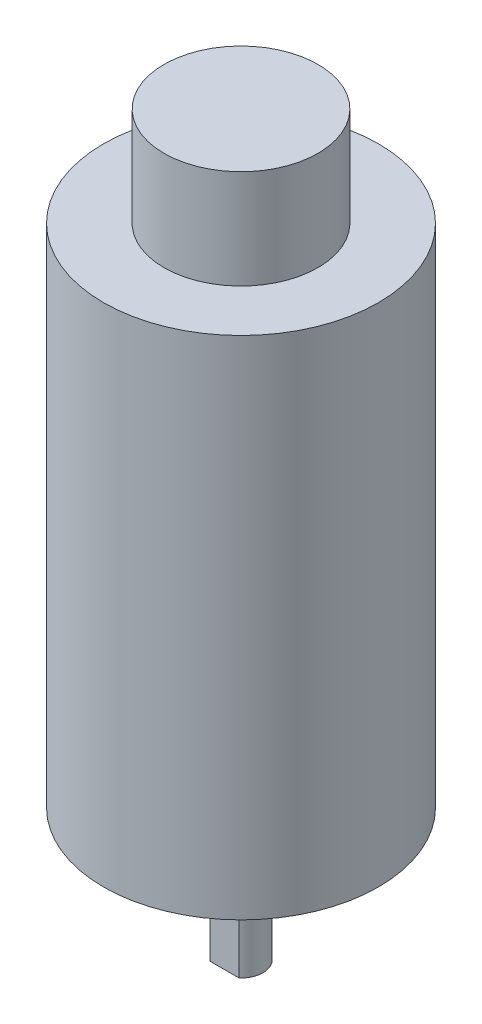
from build123d import *

# Parameters (mm, degrees)
SKETCH1_R           = 12.5
BODY_DEPTH          = 46
SKETCH2_R           = 7
BOSS_EXTRUDE4_DEPTH = 9
SKETCH5_R           = 3.5
SKETCH5_R_2         = 2
BOSS_EXTRUDE5_DEPTH = 2.5
SKETCH10_R          = 2
BOSS_EXTRUDE6_DEPTH = 12
CUT_EXTRUDE1_DEPTH  = 8
SKETCH13_R          = 1.5
CUT_EXTRUDE2_DEPTH  = 4


with BuildPart() as part:
    # Sketch1 → Body (new body)
    with BuildSketch(Plane(origin=(0, 0, 0), x_dir=(1, 0, 0), z_dir=(0, 1, 0))):
        Circle(SKETCH1_R)
    extrude(amount=BODY_DEPTH)

    # Sketch2 → Boss-Extrude4 (add)
    with BuildSketch(Plane(origin=(0, 46, 0), x_dir=(1, 0, 0), z_dir=(0, 1, 0))):
        Circle(SKETCH2_R)
    extrude(amount=BOSS_EXTRUDE4_DEPTH)

    # Sketch5 → Boss-Extrude5 (add)
    with BuildSketch(Plane(origin=(0, 0, 0), x_dir=(1, 0, 0), z_dir=(0, 1, 0))):
        Circle(SKETCH5_R)
        Circle(SKETCH5_R_2, mode=Mode.SUBTRACT)
    extrude(amount=-BOSS_EXTRUDE5_DEPTH)

    # Sketch10 → Boss-Extrude6 (add)
    with BuildSketch(Plane(origin=(0, 0, 0), x_dir=(1, 0, 0), z_dir=(0, 1, 0))):
        Circle(SKETCH10_R)
    extrude(amount=-BOSS_EXTRUDE6_DEPTH)

    # Sketch12 → Cut-Extrude1 (cut)
    with BuildSketch(Plane.XZ.offset(12)):
        with BuildLine():
            Line((-1.322875656, 1.5), (1.322875656, 1.5))
            ThreePointArc((1.322875656, 1.5), (0, 2), (-1.322875656, 1.5))
        make_face()
    extrude(amount=-CUT_EXTRUDE1_DEPTH, mode=Mode.SUBTRACT)

    # Sketch13 → Cut-Extrude2 (cut)
    with BuildSketch(Plane(origin=(0, 0, 0), x_dir=(1, 0, 0), z_dir=(0, 1, 0))):
        with Locations((0, 8.5)):
            Circle(SKETCH13_R)
        with Locations((0, -8.5)):
            Circle(SKETCH13_R)
    extrude(amount=CUT_EXTRUDE2_DEPTH, mode=Mode.SUBTRACT)


solid = part.part
